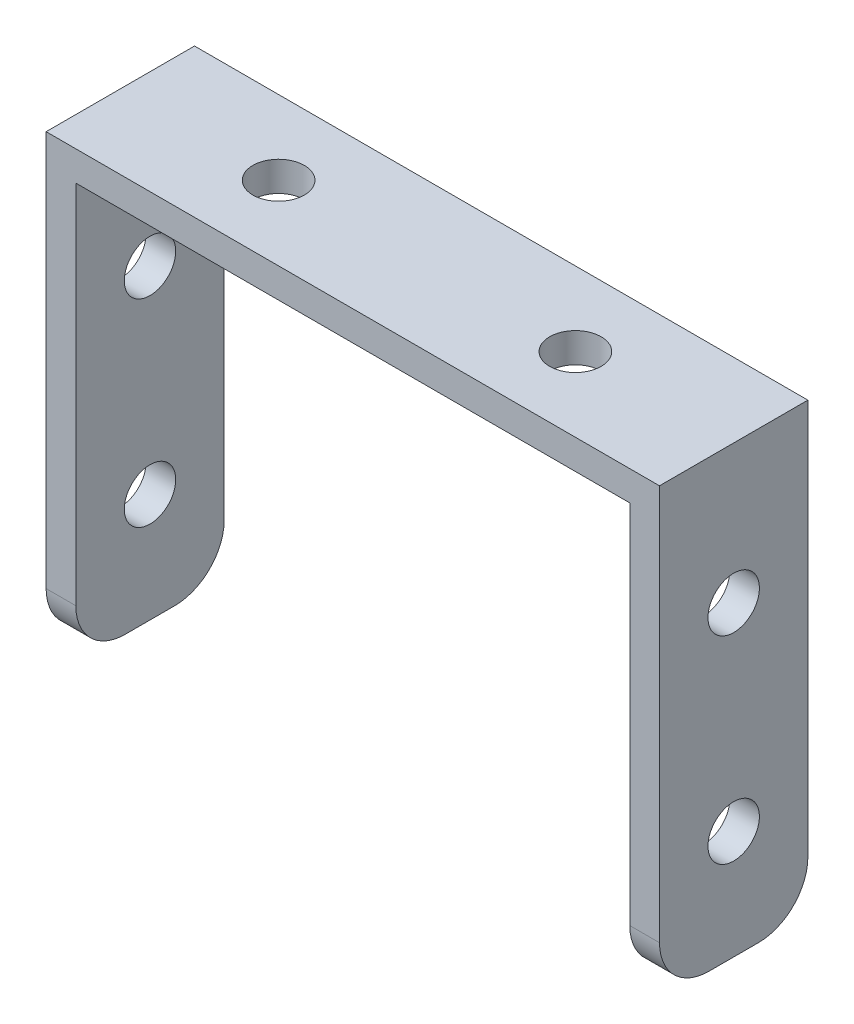
from build123d import *

# Parameters (mm, degrees)
RESSALTO_EXTRUS_O1_DEPTH = 15
ESBO_O2_R                = 2.6
CORTE_EXTRUS_O1_DEPTH    = 15
ESBO_O3_R                = 2.6
CORTE_EXTRUS_O2_DEPTH    = 63
FILETE1_R                = 5


with BuildPart() as part:
    # Esboço1 → Ressalto-extrusão1 (new body)
    with BuildSketch(Plane.XY):
        Polygon((-31, 0), (-28, 0), (-28, 42), (28, 42), (28, 0), (31, 0), (31, 45), (-31, 45), align=None)
    extrude(amount=RESSALTO_EXTRUS_O1_DEPTH)

    # Esboço2 → Corte-extrusão1 (cut)
    with BuildSketch(Plane(origin=(0, 45, 0), x_dir=(1, 0, 0), z_dir=(0, 1, 0))):
        with Locations((-15, -7.5)):
            Circle(ESBO_O2_R)
        with Locations((15, -7.5)):
            Circle(ESBO_O2_R)
    extrude(amount=-CORTE_EXTRUS_O1_DEPTH, mode=Mode.SUBTRACT)

    # Esboço3 → Corte-extrusão2 (cut, through all)
    with BuildSketch(Plane(origin=(31, 0, 0), x_dir=(0, 0, -1), z_dir=(1, 0, 0))):
        with Locations((-7.5, 11)):
            Circle(ESBO_O3_R)
        with Locations((-7.5, 31)):
            Circle(ESBO_O3_R)
    extrude(amount=-CORTE_EXTRUS_O2_DEPTH, mode=Mode.SUBTRACT)

    # Filete1
    filete1_edges = [part.edges().sort_by_distance(p)[0] for p in [
        (-29.5, 0, 0),
        (29.5, 0, 15),
        (-29.5, 0, 15),
        (29.5, 0, 0),
    ]]
    fillet(filete1_edges, radius=FILETE1_R)


solid = part.part
